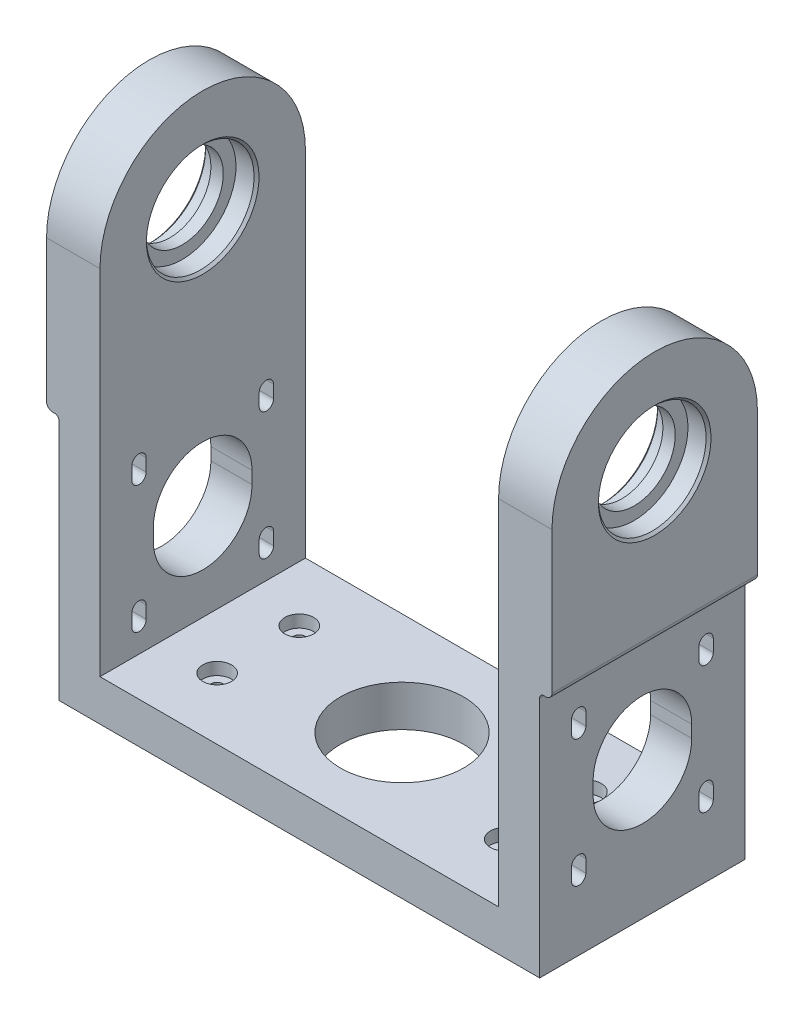
from build123d import *

# Parameters (mm, degrees)
BOSS_EXTRUDE1_DEPTH = 50
CUT_EXTRUDE1_DEPTH  = 121
SKETCH3_R           = 13.1
CUT_EXTRUDE2_DEPTH  = 5
CUT_EXTRUDE3_START  = -123
SKETCH3_3_R         = 13.1
CUT_EXTRUDE3_DEPTH  = 5
CUT_EXTRUDE4_START  = -13
SKETCH3_4_R         = 13.1
CUT_EXTRUDE4_DEPTH  = 5
CUT_EXTRUDE5_START  = -110
SKETCH3_5_R         = 13.1
CUT_EXTRUDE5_DEPTH  = 5
SKETCH4_R           = 10
CUT_EXTRUDE6_DEPTH  = 119
CHAMFER1_SIZE       = 0.6
CUT_EXTRUDE7_DEPTH  = 124
SKETCH7_R           = 15
CUT_EXTRUDE8_DEPTH  = 10
SKETCH6_R           = 1.5
CUT_EXTRUDE9_DEPTH  = 10
SKETCH8_R           = 3.5
CUT_EXTRUDE10_DEPTH = 3


with BuildPart() as part:
    # Sketch1 → Boss-Extrude1 (new body)
    with BuildSketch(Plane.XY):
        with BuildLine():
            Line((10, 128), (-3, 128))
            Line((-3, 128), (-3, 61.5))
            ThreePointArc((-3, 61.5), (-2.560660172, 60.439339828), (-1.5, 60))
            Line((-1.5, 60), (-1, 60))
            ThreePointArc((-1, 60), (-0.292893219, 59.707106781), (0, 59))
            Line((0, 59), (0, 0))
            Line((0, 0), (117, 0))
            Line((117, 0), (117, 59))
            ThreePointArc((117, 59), (117.292893219, 59.707106781), (118, 60))
            Line((118, 60), (118.5, 60))
            ThreePointArc((118.5, 60), (119.560660172, 60.439339828), (120, 61.5))
            Line((120, 61.5), (120, 128))
            Line((120, 128), (107, 128))
            Line((107, 128), (107, 10))
            Line((107, 10), (10, 10))
            Line((10, 10), (10, 128))
        make_face()
    extrude(amount=BOSS_EXTRUDE1_DEPTH)

    # Sketch2 → Cut-Extrude1 (cut, through all)
    with BuildSketch(Plane(origin=(117, 0, 0), x_dir=(0, 0, -1), z_dir=(1, 0, 0))):
        with BuildLine():
            Line((-42.25, 47.5), (-42.25, 50.5))
            ThreePointArc((-42.25, 50.5), (-40.5, 52.25), (-38.75, 50.5))
            Line((-38.75, 50.5), (-38.75, 47.5))
            ThreePointArc((-38.75, 47.5), (-40.5, 45.75), (-42.25, 47.5))
        make_face()
        with BuildLine():
            Line((-37, 35), (-37, 32))
            ThreePointArc((-37, 32), (-25, 20), (-13, 32))
            Line((-13, 32), (-13, 35))
            ThreePointArc((-13, 35), (-25, 47), (-37, 35))
        make_face()
        with BuildLine():
            Line((-11.25, 50.5), (-11.25, 47.5))
            ThreePointArc((-11.25, 47.5), (-9.5, 45.75), (-7.75, 47.5))
            Line((-7.75, 47.5), (-7.75, 50.5))
            ThreePointArc((-7.75, 50.5), (-9.5, 52.25), (-11.25, 50.5))
        make_face()
        with BuildLine():
            Line((-11.25, 19.5), (-11.25, 16.5))
            ThreePointArc((-11.25, 16.5), (-9.5, 14.75), (-7.75, 16.5))
            Line((-7.75, 16.5), (-7.75, 19.5))
            ThreePointArc((-7.75, 19.5), (-9.5, 21.25), (-11.25, 19.5))
        make_face()
        with BuildLine():
            Line((-38.75, 19.5), (-38.75, 16.5))
            ThreePointArc((-38.75, 16.5), (-40.5, 14.75), (-42.25, 16.5))
            Line((-42.25, 16.5), (-42.25, 19.5))
            ThreePointArc((-42.25, 19.5), (-40.5, 21.25), (-38.75, 19.5))
        make_face()
    extrude(amount=-CUT_EXTRUDE1_DEPTH, mode=Mode.SUBTRACT)

    # Sketch3 → Cut-Extrude2 (cut)
    with BuildSketch(Plane(origin=(120, 0, 0), x_dir=(0, 0, -1), z_dir=(1, 0, 0))):
        with Locations((-25, 96)):
            Circle(SKETCH3_R)
    extrude(amount=-CUT_EXTRUDE2_DEPTH, mode=Mode.SUBTRACT)

    # Sketch3_3 → Cut-Extrude3 (cut)
    with BuildSketch(Plane(origin=(120, 0, 0), x_dir=(0, 0, -1), z_dir=(1, 0, 0)).offset(CUT_EXTRUDE3_START)):
        with Locations((-25, 96)):
            Circle(SKETCH3_3_R)
    extrude(amount=CUT_EXTRUDE3_DEPTH, mode=Mode.SUBTRACT)

    # Sketch3_4 → Cut-Extrude4 (cut)
    with BuildSketch(Plane(origin=(120, 0, 0), x_dir=(0, 0, -1), z_dir=(1, 0, 0)).offset(CUT_EXTRUDE4_START)):
        with Locations((-25, 96)):
            Circle(SKETCH3_4_R)
    extrude(amount=CUT_EXTRUDE4_DEPTH, mode=Mode.SUBTRACT)

    # Sketch3_5 → Cut-Extrude5 (cut)
    with BuildSketch(Plane(origin=(120, 0, 0), x_dir=(0, 0, -1), z_dir=(1, 0, 0)).offset(CUT_EXTRUDE5_START)):
        with Locations((-25, 96)):
            Circle(SKETCH3_5_R)
    extrude(amount=-CUT_EXTRUDE5_DEPTH, mode=Mode.SUBTRACT)

    # Sketch4 → Cut-Extrude6 (cut, through all)
    with BuildSketch(Plane(origin=(115, 0, 0), x_dir=(0, 0, -1), z_dir=(1, 0, 0))):
        with Locations((-25, 96)):
            Circle(SKETCH4_R)
    extrude(amount=-CUT_EXTRUDE6_DEPTH, mode=Mode.SUBTRACT)

    # Chamfer1
    chamfer1_edges = [part.edges().sort_by_distance(p)[0] for p in [
        (120, 96, 38.1),
        (-3, 96, 38.1),
        (107, 96, 38.1),
        (10, 96, 38.1),
    ]]
    chamfer(chamfer1_edges, length=CHAMFER1_SIZE)

    # Sketch5 → Cut-Extrude7 (cut, through all)
    with BuildSketch(Plane.ZY.offset(3)):
        with BuildLine():
            Line((0, 96), (0, 151.710807056))
            Line((0, 151.710807056), (50, 151.710807056))
            Line((50, 151.710807056), (50, 96))
            ThreePointArc((50, 96), (25, 121), (0, 96))
        make_face()
    extrude(amount=-CUT_EXTRUDE7_DEPTH, mode=Mode.SUBTRACT)

    # Sketch7 → Cut-Extrude8 (cut)
    with BuildSketch(Plane(origin=(0, 10, 0), x_dir=(1, 0, 0), z_dir=(0, 1, 0))):
        with Locations((58.5, -25)):
            Circle(SKETCH7_R)
    extrude(amount=-CUT_EXTRUDE8_DEPTH, mode=Mode.SUBTRACT)

    # Sketch6 → Cut-Extrude9 (cut)
    with BuildSketch(Plane(origin=(0, 0, 0), x_dir=(-1, 0, 0), z_dir=(0, -1, 0))):
        with Locations((-93.5, -15)):
            Circle(SKETCH6_R)
        with Locations((-93.5, -35)):
            Circle(SKETCH6_R)
        with Locations((-23.5, -35)):
            Circle(SKETCH6_R)
        with Locations((-23.5, -15)):
            Circle(SKETCH6_R)
    extrude(amount=-CUT_EXTRUDE9_DEPTH, mode=Mode.SUBTRACT)

    # Sketch8 → Cut-Extrude10 (cut)
    with BuildSketch(Plane(origin=(0, 10, 0), x_dir=(1, 0, 0), z_dir=(0, 1, 0))):
        with Locations((23.5, -15)):
            Circle(SKETCH8_R)
        with Locations((23.5, -35)):
            Circle(SKETCH8_R)
        with Locations((93.5, -35)):
            Circle(SKETCH8_R)
        with Locations((93.5, -15)):
            Circle(SKETCH8_R)
    extrude(amount=-CUT_EXTRUDE10_DEPTH, mode=Mode.SUBTRACT)


solid = part.part
